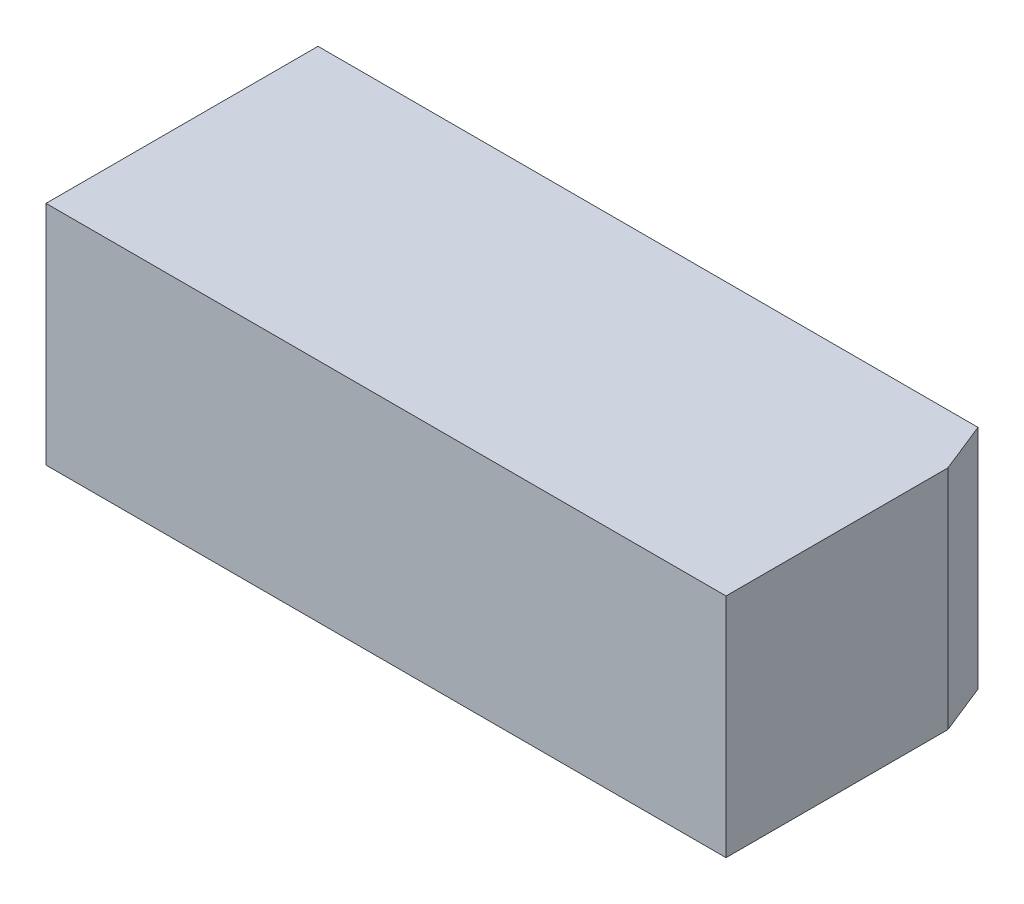
from build123d import *

# Parameters (mm, degrees)
SKETCH1_W              = 15
SKETCH1_H              = 6
MAIN_BODY_DEPTH        = 5
SKETCH3_R              = 1.25
GRIN_HOLE_DEPTH        = 4
SKETCH2_R              = 0.795
MAGNET_HOLES_DEPTH     = 1
SET_SCREW_INDENT_DEPTH = 6


with BuildPart() as part:
    # Sketch1 → Main Body (new body)
    with BuildSketch(Plane(origin=(0, 0, 0), x_dir=(1, 0, 0), z_dir=(0, 1, 0))):
        Rectangle(SKETCH1_W, SKETCH1_H)
    extrude(amount=MAIN_BODY_DEPTH)

    # Sketch3 → GRIN Hole (cut)
    with BuildSketch(Plane.XZ):
        with Locations((-4.5, 0)):
            Circle(SKETCH3_R)
    extrude(amount=-GRIN_HOLE_DEPTH, mode=Mode.SUBTRACT)

    # Sketch2 → Magnet Holes (cut)
    with BuildSketch(Plane.XZ):
        with Locations((-6.25, -1.875)):
            Circle(SKETCH2_R)
        with Locations((-6.25, 1.875)):
            Circle(SKETCH2_R)
        with Locations((2.5, 0)):
            Circle(SKETCH2_R)
    extrude(amount=-MAGNET_HOLES_DEPTH, mode=Mode.SUBTRACT)

    # Sketch4 → Set Screw Indent (cut, through all)
    with BuildSketch(Plane.XZ):
        Polygon((7.058045095, -3), (7.5, -1.895112738), (7.5, -3), align=None)
    extrude(amount=-SET_SCREW_INDENT_DEPTH, mode=Mode.SUBTRACT)


solid = part.part
